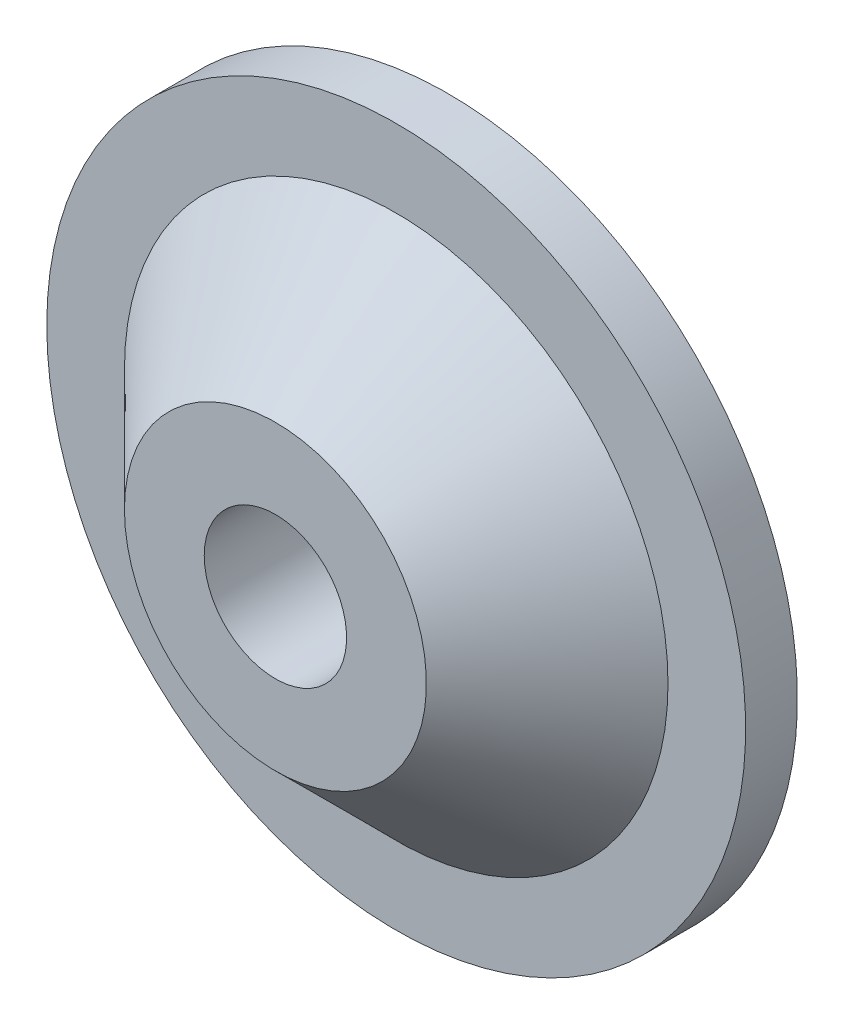
from build123d import *

# Parameters (mm, degrees)
CHAMFER1_SIZE = 0.5


with BuildPart() as part:
    # Sketch3 → Revolve1 (revolve)
    with BuildSketch(Plane(origin=(0, 0, 0), x_dir=(1, 0, 0), z_dir=(0, 1, 0))):
        Polygon((6.3, 0), (8.1, 0), (8.1, 1.2), (1.65, 1.2), (1.65, 0), (1.65, -2.8), (3.5, -2.8), align=None)
    revolve(axis=Axis((0, 0, -35.580076817), (0, 0, 1)))

    # Chamfer1
    chamfer1_edges = [part.edges().sort_by_distance(p)[0] for p in [
        (-1.65, 0, -1.2),
    ]]
    chamfer(chamfer1_edges, length=CHAMFER1_SIZE)


solid = part.part
